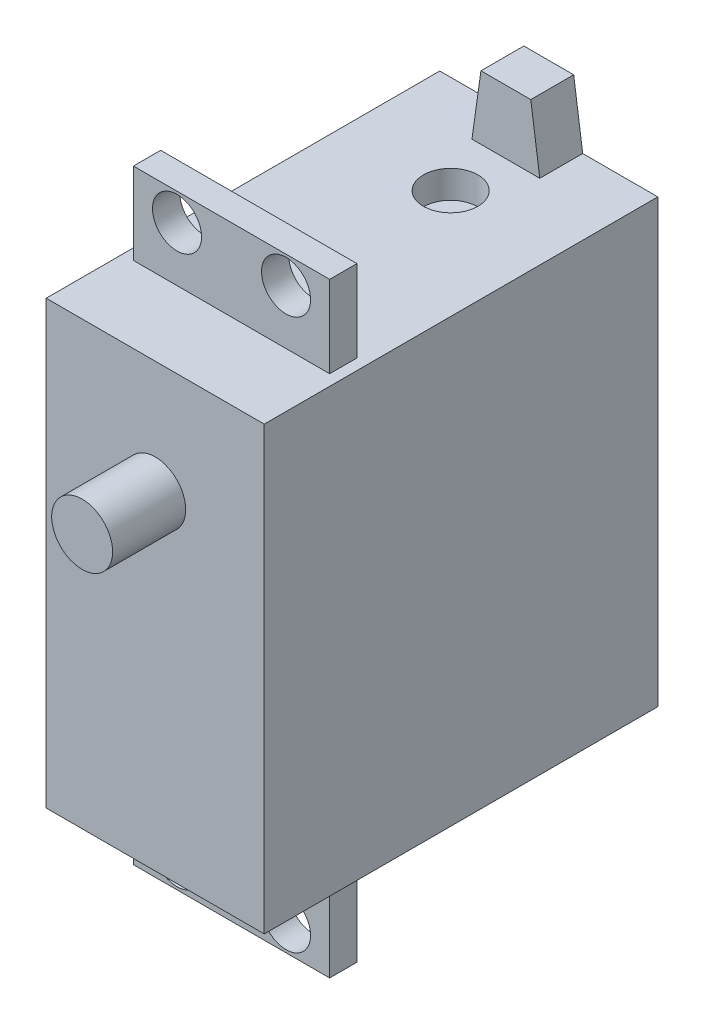
from build123d import *

# Parameters (mm, degrees)
SKETCH1_W           = 20
SKETCH1_H           = 40.5
BOSS_EXTRUDE1_DEPTH = 9.50000005
SKETCH2_W           = 20
SKETCH2_H           = 40.5
BOSS_EXTRUDE2_DEPTH = 17.1
SKETCH3_R           = 2.25
BOSS_EXTRUDE3_DEPTH = 2.5
SKETCH4_R           = 2.794
BOSS_EXTRUDE4_DEPTH = 6.702060002
SKETCH7_R           = 2.5
CUT_EXTRUDE1_DEPTH  = 2.54
BOSS_EXTRUDE6_DEPTH = 3.937


with BuildPart() as part:
    # Sketch1 → Boss-Extrude1 (new body, symmetric)
    with BuildSketch(Plane.XY):
        with Locations((10, 20.25)):
            Rectangle(SKETCH1_W, SKETCH1_H)
    extrude(amount=BOSS_EXTRUDE1_DEPTH, both=True)

    # Sketch2 → Boss-Extrude2 (add)
    with BuildSketch(Plane(origin=(0, 0, -9.50000005), x_dir=(-1, 0, 0), z_dir=(0, 0, -1))):
        with Locations((-10, 20.25)):
            Rectangle(SKETCH2_W, SKETCH2_H)
    extrude(amount=BOSS_EXTRUDE2_DEPTH)

    # Sketch3 → Boss-Extrude3 (add)
    with BuildSketch(Plane.XY):
        Polygon((19, 0), (19, -7.5), (1, -7.5), (1, 0), (0, 0), (0, 40.5), (1, 40.5), (1, 48), (19, 48), (19, 40.5), (20, 40.5), (20, 0), align=None)
        with Locations((5, -5)):
            Circle(SKETCH3_R, mode=Mode.SUBTRACT)
        with Locations((15, -5)):
            Circle(SKETCH3_R, mode=Mode.SUBTRACT)
        with Locations((5, 45.5)):
            Circle(SKETCH3_R, mode=Mode.SUBTRACT)
        with Locations((15, 45.5)):
            Circle(SKETCH3_R, mode=Mode.SUBTRACT)
    extrude(amount=BOSS_EXTRUDE3_DEPTH)

    # Sketch4 → Boss-Extrude4 (add)
    with BuildSketch(Plane.XY.offset(9.50000005)):
        with Locations((10, 30.1)):
            Circle(SKETCH4_R)
    extrude(amount=BOSS_EXTRUDE4_DEPTH)

    # Sketch7 → Cut-Extrude1 (cut)
    with BuildSketch(Plane(origin=(0, 40.5, 0), x_dir=(1, 0, 0), z_dir=(0, 1, 0))):
        with Locations((10, 17.60000005)):
            Circle(SKETCH7_R)
    extrude(amount=-CUT_EXTRUDE1_DEPTH, mode=Mode.SUBTRACT)

    # Sketch9 → Boss-Extrude6 (add)
    with BuildSketch(Plane(origin=(0, 0, -26.60000005), x_dir=(-1, 0, 0), z_dir=(0, 0, -1))):
        Polygon((-13.1115, 40.5), (-6.8885, 40.5), (-7.714, 46.342), (-12.286, 46.342), align=None)
    extrude(amount=-BOSS_EXTRUDE6_DEPTH)


solid = part.part
